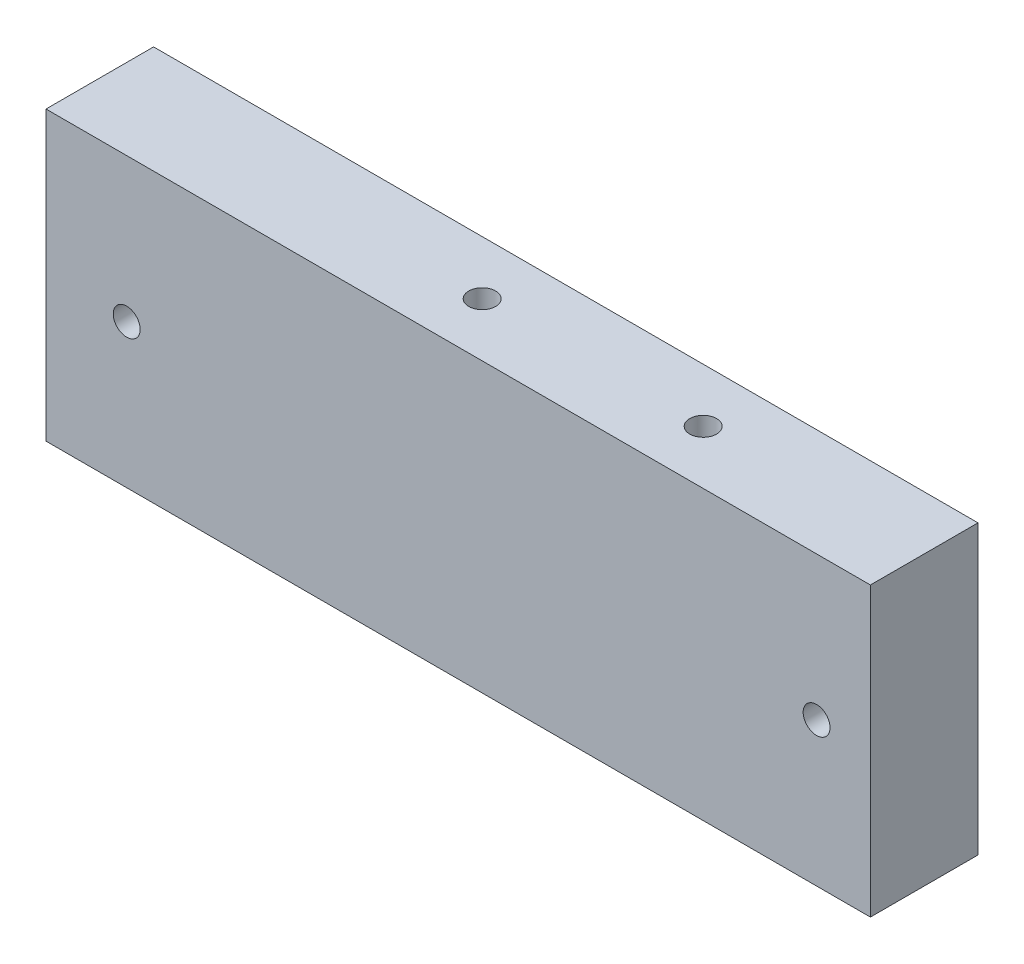
from build123d import *

# Parameters (mm, degrees)
SKETCH1_W           = 97.3
SKETCH1_H           = 33.95
BOSS_EXTRUDE1_DEPTH = 12.7
HOLE1_D             = 3.175
HOLE1_DEPTH         = 31.75
HOLE1_CSINK_D       = 10.16
HOLE1_CSINK_ANGLE   = 82
HOLE1_TIP           = 0.953866233
HOLE2_D             = 3.175
HOLE2_DEPTH         = 31.75
HOLE2_CSINK_D       = 10.16
HOLE2_CSINK_ANGLE   = 82
HOLE2_TIP           = 0.953866233
HOLE5_D             = 3.175
HOLE5_DEPTH         = 31.75
HOLE5_CSINK_D       = 10.16
HOLE5_CSINK_ANGLE   = 82
HOLE5_TIP           = 0.953866233
HOLE6_D             = 3.175
HOLE6_DEPTH         = 31.75
HOLE6_CSINK_D       = 10.16
HOLE6_CSINK_ANGLE   = 82
HOLE6_TIP           = 0.953866233


with BuildPart() as part:
    # Sketch1 → Boss-Extrude1 (new body)
    with BuildSketch(Plane.XY):
        with Locations((-292.654465963, -36.025)):
            Rectangle(SKETCH1_W, SKETCH1_H)
    extrude(amount=-BOSS_EXTRUDE1_DEPTH)

    # Hole1
    with Locations(Plane(origin=(-124.004465969, 0, -10.424290059), x_dir=(-1, 0, 0), z_dir=(0, 1, 0))):
        with Locations((126.349999994, 161.374290059), (146.083333327, 4.074290059), (172.166666661, 4.074290059), (126.349999994, 34.524290059), (126.349999994, 130.924290059), (-172.166666661, 4.074290059), (-146.083333327, 4.074290059), (-126.349999994, 34.524290059), (-126.349999994, 130.924290059), (-126.349999994, 161.374290059)):
            CounterSinkHole(HOLE1_D / 2, HOLE1_CSINK_D / 2, depth=HOLE1_DEPTH, counter_sink_angle=HOLE1_CSINK_ANGLE)
            with Locations((0, 0, -(HOLE1_DEPTH + HOLE1_TIP / 2))):  # 118° drill point
                Cone(0, HOLE1_D / 2, HOLE1_TIP, mode=Mode.SUBTRACT)

    # Hole2
    with Locations(Plane(origin=(-124.004465969, -72.05, -10.424290059), x_dir=(1, 0, 0), z_dir=(0, -1, 0))):
        with Locations((126.349999994, 161.374290059), (146.083333327, 4.074290059), (172.166666661, 4.074290059), (126.349999994, 34.524290059), (126.349999994, 130.924290059), (-172.166666661, 4.074290059), (-146.083333327, 4.074290059), (-126.349999994, 34.524290059), (-126.349999994, 130.924290059), (-126.349999994, 161.374290059)):
            CounterSinkHole(HOLE2_D / 2, HOLE2_CSINK_D / 2, depth=HOLE2_DEPTH, counter_sink_angle=HOLE2_CSINK_ANGLE)
            with Locations((0, 0, -(HOLE2_DEPTH + HOLE2_TIP / 2))):  # 118° drill point
                Cone(0, HOLE2_D / 2, HOLE2_TIP, mode=Mode.SUBTRACT)

    # Hole5
    with Locations(Plane(origin=(-124.004465969, -208.286738577, -12.7), x_dir=(-1, 0, 0), z_dir=(0, 0, -1))):
        with Locations((207.774999994, 172.261738577), (126.349999994, 172.261738577)):
            CounterSinkHole(HOLE5_D / 2, HOLE5_CSINK_D / 2, depth=HOLE5_DEPTH, counter_sink_angle=HOLE5_CSINK_ANGLE)
            with Locations((0, 0, -(HOLE5_DEPTH + HOLE5_TIP / 2))):  # 118° drill point
                Cone(0, HOLE5_D / 2, HOLE5_TIP, mode=Mode.SUBTRACT)

    # Hole6
    with Locations(Plane(origin=(-124.004465969, -6.35, -10.424290059), x_dir=(-1, 0, 0), z_dir=(0, 1, 0))):
        with Locations((-207.774999994, 333.02141023), (-207.774999994, 225.48903684), (-207.774999994, 137.424290059), (-172.166666661, 4.074290059), (-146.083333327, 4.074290059), (-94.599999994, 161.374290059), (94.599999994, 161.374290059), (146.083333327, 4.074290059), (172.166666661, 4.074290059), (207.774999994, 137.424290059), (207.774999994, 225.48903684), (207.774999994, 333.02141023), (166.795833328, 301.970350905), (40.979166666, 301.970350905), (-40.979166666, 301.970350905), (-166.795833328, 301.970350905), (0, 193.124290059), (0, 301.970350905), (0, 412.366411751), (-126.349999994, 106.824290059), (-126.349999994, 58.624290059), (126.349999994, 58.624290059), (126.349999994, 106.824290059)):
            CounterSinkHole(HOLE6_D / 2, HOLE6_CSINK_D / 2, depth=HOLE6_DEPTH, counter_sink_angle=HOLE6_CSINK_ANGLE)
            with Locations((0, 0, -(HOLE6_DEPTH + HOLE6_TIP / 2))):  # 118° drill point
                Cone(0, HOLE6_D / 2, HOLE6_TIP, mode=Mode.SUBTRACT)


solid = part.part
